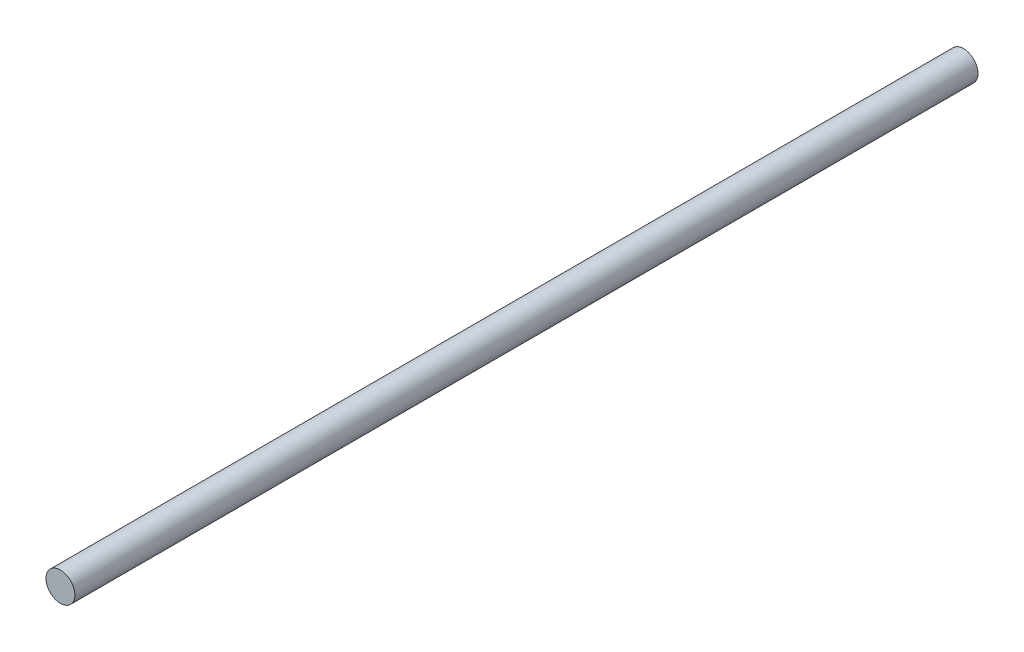
from build123d import *

# Parameters (mm, degrees)
SKETCH1_R           = 4
BOSS_EXTRUDE1_DEPTH = 250


with BuildPart() as part:
    # Sketch1 → Boss-Extrude1 (new body)
    with BuildSketch(Plane.XY):
        Circle(SKETCH1_R)
    extrude(amount=BOSS_EXTRUDE1_DEPTH)


solid = part.part
